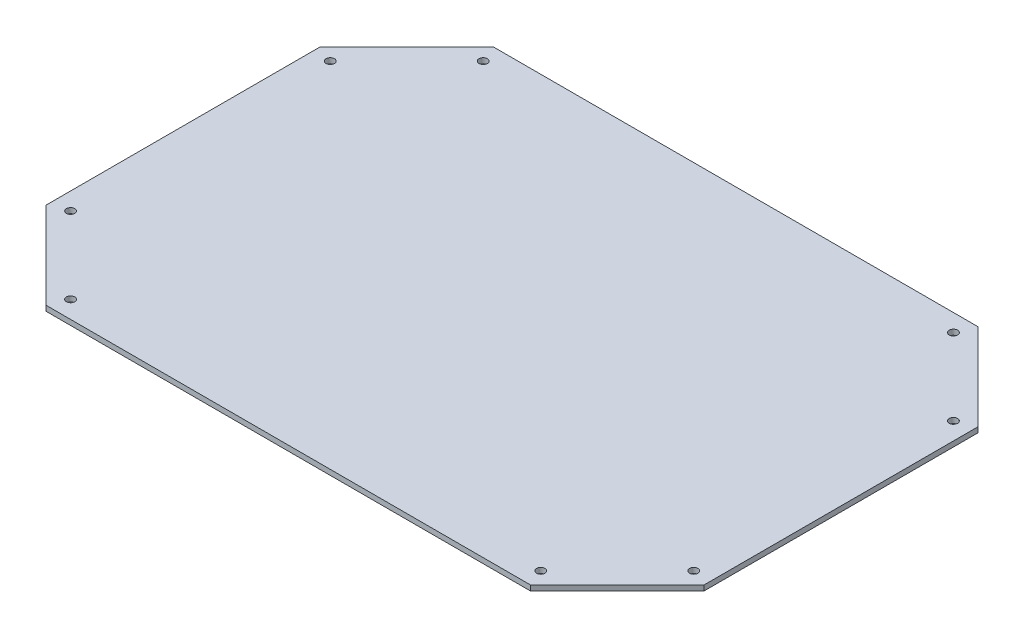
from build123d import *

# Parameters (mm, degrees)
SKETCH1_R           = 1.6
BOSS_EXTRUDE1_DEPTH = 2


with BuildPart() as part:
    # Sketch1 → Boss-Extrude1 (new body)
    with BuildSketch(Plane(origin=(0, 0, 0), x_dir=(1, 0, 0), z_dir=(0, 1, 0))):
        Polygon((125, 52.071067812), (92.071067812, 85), (-92.071067812, 85), (-125, 52.071067812), (-125, -52.071067812), (-92.071067812, -85), (92.071067812, -85), (125, -52.071067812), align=None)
        with Locations((-89.3372583, -78.4)):
            Circle(SKETCH1_R, mode=Mode.SUBTRACT)
        with Locations((-118.4, -49.3372583)):
            Circle(SKETCH1_R, mode=Mode.SUBTRACT)
        with Locations((-118.4, 49.3372583)):
            Circle(SKETCH1_R, mode=Mode.SUBTRACT)
        with Locations((-89.3372583, 78.4)):
            Circle(SKETCH1_R, mode=Mode.SUBTRACT)
        with Locations((89.3372583, 78.4)):
            Circle(SKETCH1_R, mode=Mode.SUBTRACT)
        with Locations((118.4, 49.3372583)):
            Circle(SKETCH1_R, mode=Mode.SUBTRACT)
        with Locations((118.4, -49.3372583)):
            Circle(SKETCH1_R, mode=Mode.SUBTRACT)
        with Locations((89.3372583, -78.4)):
            Circle(SKETCH1_R, mode=Mode.SUBTRACT)
    extrude(amount=BOSS_EXTRUDE1_DEPTH)


solid = part.part
